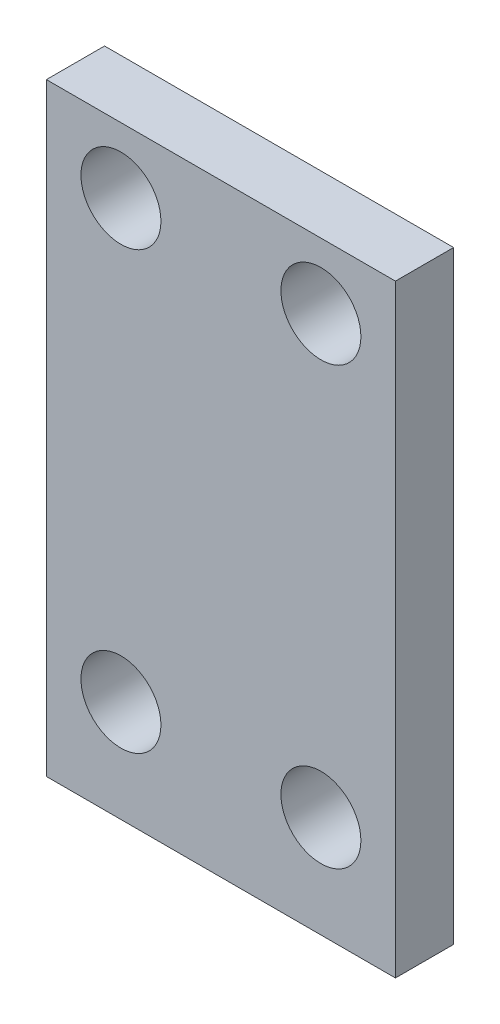
from build123d import *

# Parameters (mm, degrees)
SKETCH_2_W      = 9.6
SKETCH_2_H      = 16.6
SKETCH_2_R      = 1.1
EXTRUDE_1_DEPTH = 1.6


with BuildPart() as part:
    # 草图2 → 凸台-拉伸1 (new body)
    with BuildSketch(Plane.XY):
        with Locations((5, 11.5)):
            Rectangle(SKETCH_2_W, SKETCH_2_H)
        with Locations((2.25, 6)):
            Circle(SKETCH_2_R, mode=Mode.SUBTRACT)
        with Locations((2.25, 18)):
            Circle(SKETCH_2_R, mode=Mode.SUBTRACT)
        with Locations((7.75, 18)):
            Circle(SKETCH_2_R, mode=Mode.SUBTRACT)
        with Locations((7.75, 6)):
            Circle(SKETCH_2_R, mode=Mode.SUBTRACT)
    extrude(amount=EXTRUDE_1_DEPTH)


solid = part.part
